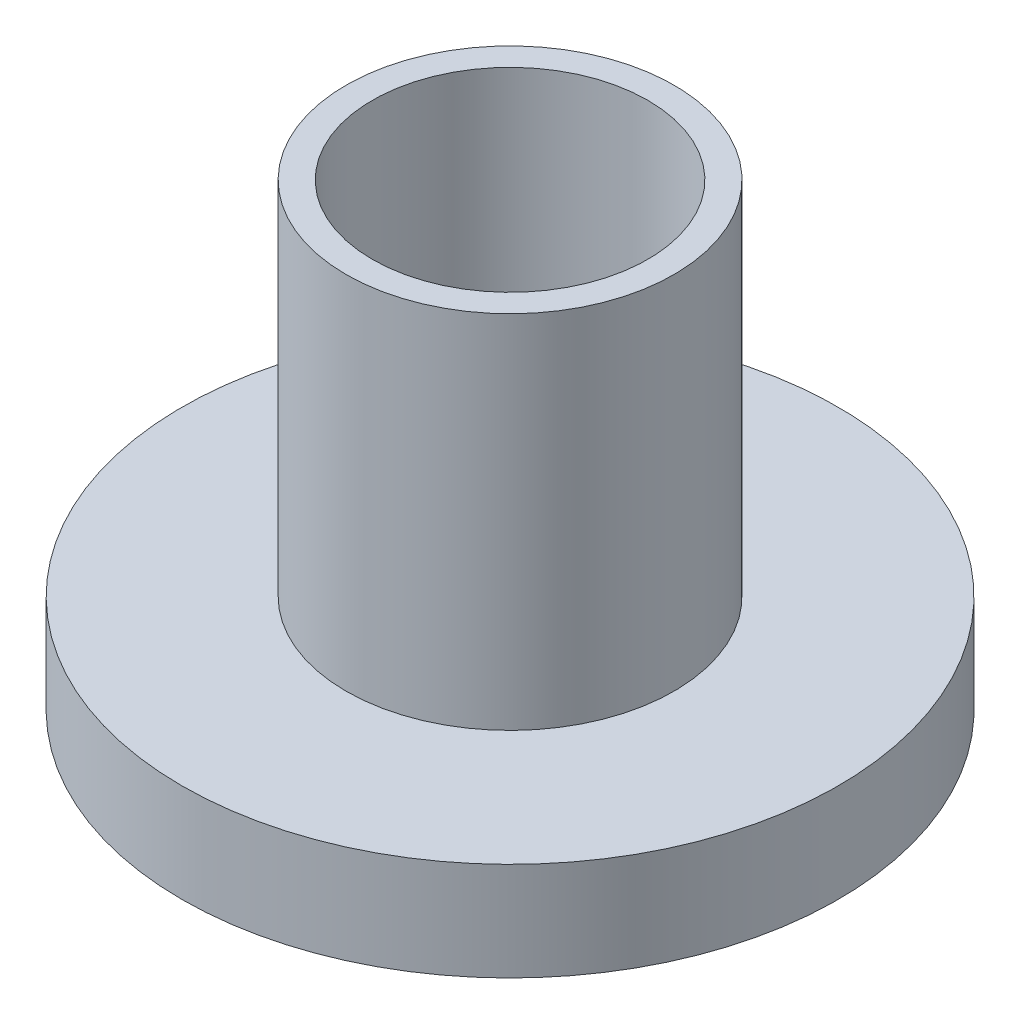
from build123d import *

# Parameters (mm, degrees)
SKETCH_1_R      = 2.5
SKETCH_1_R_2    = 2.1
EXTRUDE_1_DEPTH = 5.5
EXTRUDE_START   = -1.5
SKETCH_1_3_R    = 5
SKETCH_1_3_R_2  = 2.1
EXTRUDE_2_DEPTH = 1.5


with BuildPart() as part:
    # 草图1 → 凸台-拉伸1 (new body)
    with BuildSketch(Plane(origin=(0, 0, 0), x_dir=(1, 0, 0), z_dir=(0, 1, 0))):
        Circle(SKETCH_1_R)
        Circle(SKETCH_1_R_2, mode=Mode.SUBTRACT)
    extrude(amount=EXTRUDE_1_DEPTH)

    # 草图1<3> → 凸台-拉伸2 (add)
    with BuildSketch(Plane(origin=(0, 0, 0), x_dir=(1, 0, 0), z_dir=(0, 1, 0)).offset(EXTRUDE_START)):
        Circle(SKETCH_1_3_R)
        Circle(SKETCH_1_3_R_2, mode=Mode.SUBTRACT)
    extrude(amount=EXTRUDE_2_DEPTH)


solid = part.part
